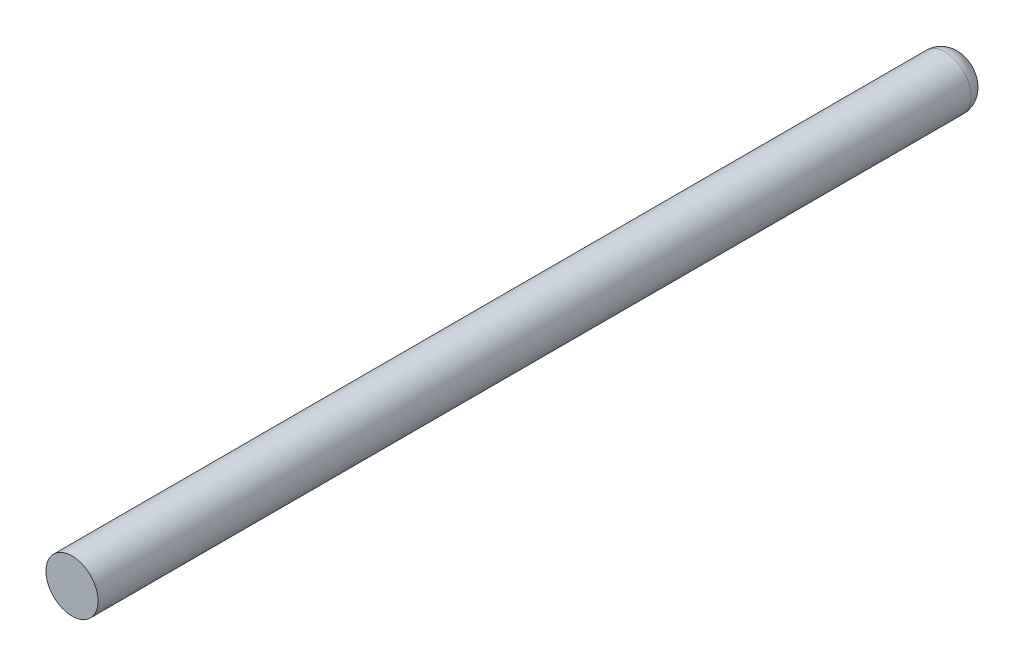
from build123d import *

# Parameters (mm, degrees)
SKETCH1_R           = 3.9751
BOSS_EXTRUDE1_DEPTH = 135.636
FILLET2_R           = 2.54


with BuildPart() as part:
    # Sketch1 → Boss-Extrude1 (new body)
    with BuildSketch(Plane.XY):
        Circle(SKETCH1_R)
    extrude(amount=BOSS_EXTRUDE1_DEPTH)

    # Fillet2
    fillet2_edges = [part.edges().sort_by_distance(p)[0] for p in [
        (-3.9751, 0, 0),
    ]]
    fillet(fillet2_edges, radius=FILLET2_R)


solid = part.part
